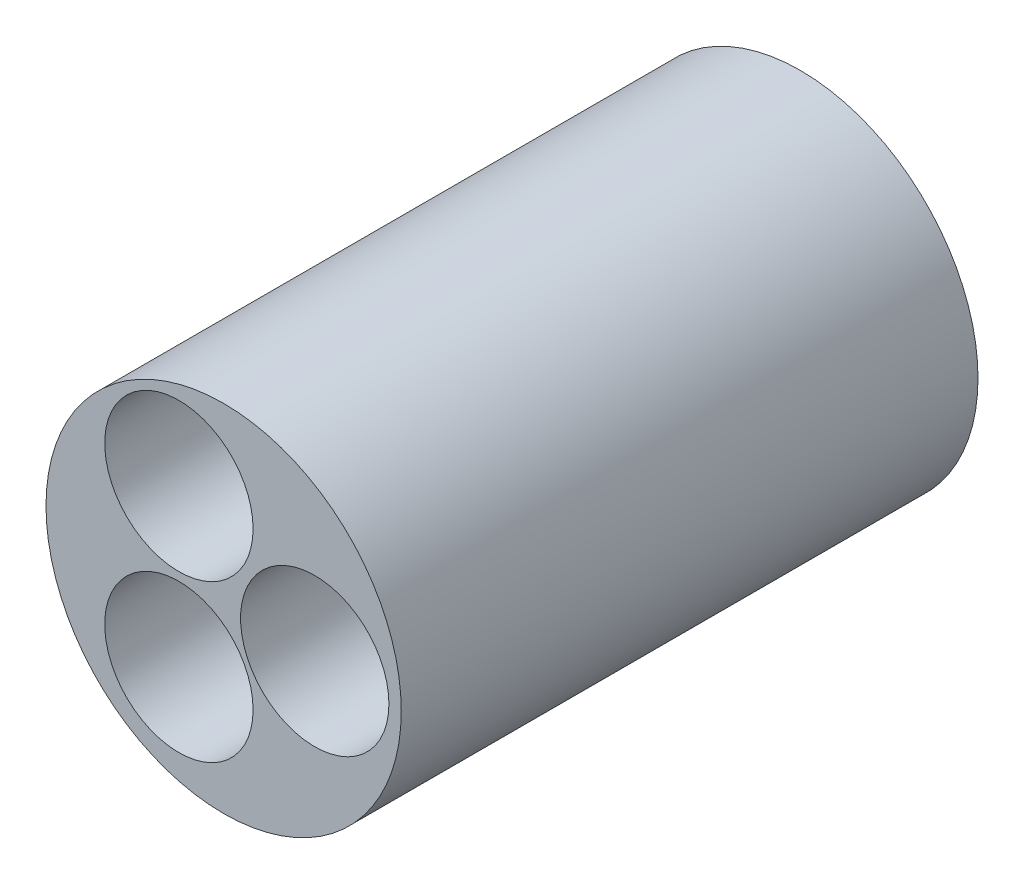
from build123d import *

# Parameters (mm, degrees)
SKETCH1_R           = 21.59
SKETCH1_R_2         = 9.017
BOSS_EXTRUDE1_DEPTH = 70.1


with BuildPart() as part:
    # Sketch1 → Boss-Extrude1 (new body)
    with BuildSketch(Plane.XY):
        with Locations((5.436965925, 8.875)):
            Circle(SKETCH1_R)
        Circle(SKETCH1_R_2, mode=Mode.SUBTRACT)
        with Locations((0, 19.05)):
            Circle(SKETCH1_R_2, mode=Mode.SUBTRACT)
        with Locations((16.51, 8.875)):
            Circle(SKETCH1_R_2, mode=Mode.SUBTRACT)
    extrude(amount=BOSS_EXTRUDE1_DEPTH)


solid = part.part
